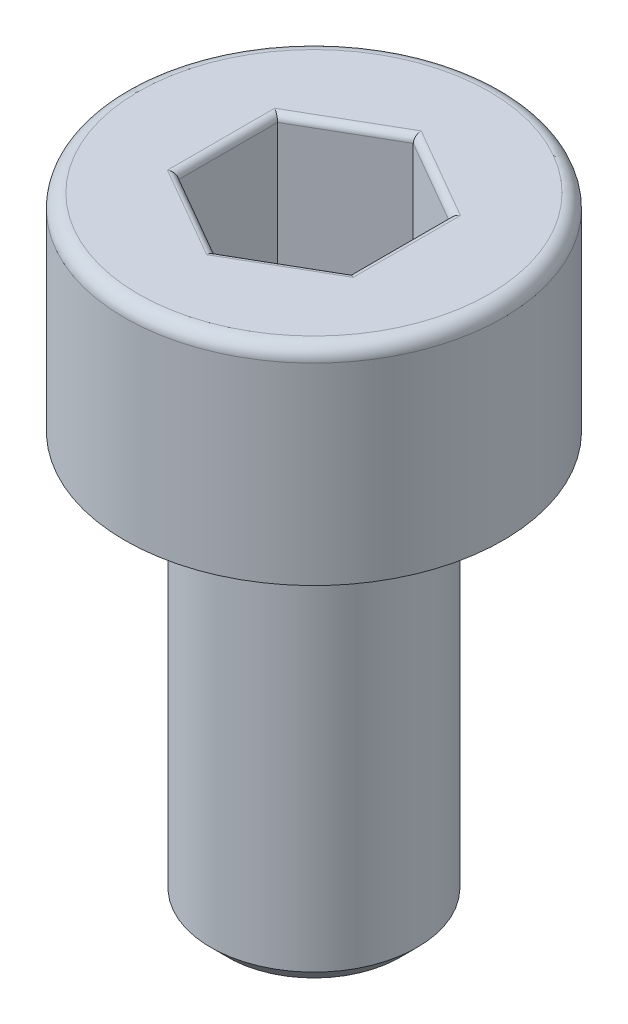
from build123d import *

# Parameters (mm, degrees)
CHAMFER1_SIZE      = 0.25
FILLET1_R          = 0.2
CUT_EXTRUDE1_DEPTH = 2
FILLET2_R          = 0.1


with BuildPart() as part:
    # Sketch1 → Revolve1 (revolve)
    with BuildSketch(Plane.XY):
        Polygon((0, -9), (-1.5, -9), (-1.5, -3), (-2.75, -3), (-2.75, 0), (0, 0), align=None)
    revolve(axis=Axis((0, 0, 0), (0, -1, 0)))

    # Chamfer1
    chamfer1_edges = [part.edges().sort_by_distance(p)[0] for p in [
        (1.5, -3, 0),
        (1.5, -9, 0),
    ]]
    chamfer(chamfer1_edges, length=CHAMFER1_SIZE)

    # Fillet1
    fillet1_edges = [part.edges().sort_by_distance(p)[0] for p in [
        (2.75, 0, 0),
    ]]
    fillet(fillet1_edges, radius=FILLET1_R)

    # Sketch2 → Cut-Extrude1 (cut)
    with BuildSketch(Plane(origin=(0, 0, 0), x_dir=(1, 0, 0), z_dir=(0, 1, 0))):
        Polygon((0, 1.443375673), (-1.25, 0.721687836), (-1.25, -0.721687836), (0, -1.443375673), (1.25, -0.721687836), (1.25, 0.721687836), align=None)
    extrude(amount=-CUT_EXTRUDE1_DEPTH, mode=Mode.SUBTRACT)

    # Fillet2
    fillet2_edges = [part.edges().sort_by_distance(p)[0] for p in [
        (0.625, -2, -1.082531755),
        (1.25, -2, 0),
        (0.625, -2, 1.082531755),
        (-0.625, -2, 1.082531755),
        (-1.25, -2, 0),
        (-0.625, -2, -1.082531755),
        (0.625, 0, -1.082531755),
        (-0.625, 0, -1.082531755),
        (-1.25, 0, 0),
        (-0.625, 0, 1.082531755),
        (0.625, 0, 1.082531755),
        (1.25, 0, 0),
    ]]
    fillet(fillet2_edges, radius=FILLET2_R)


solid = part.part
